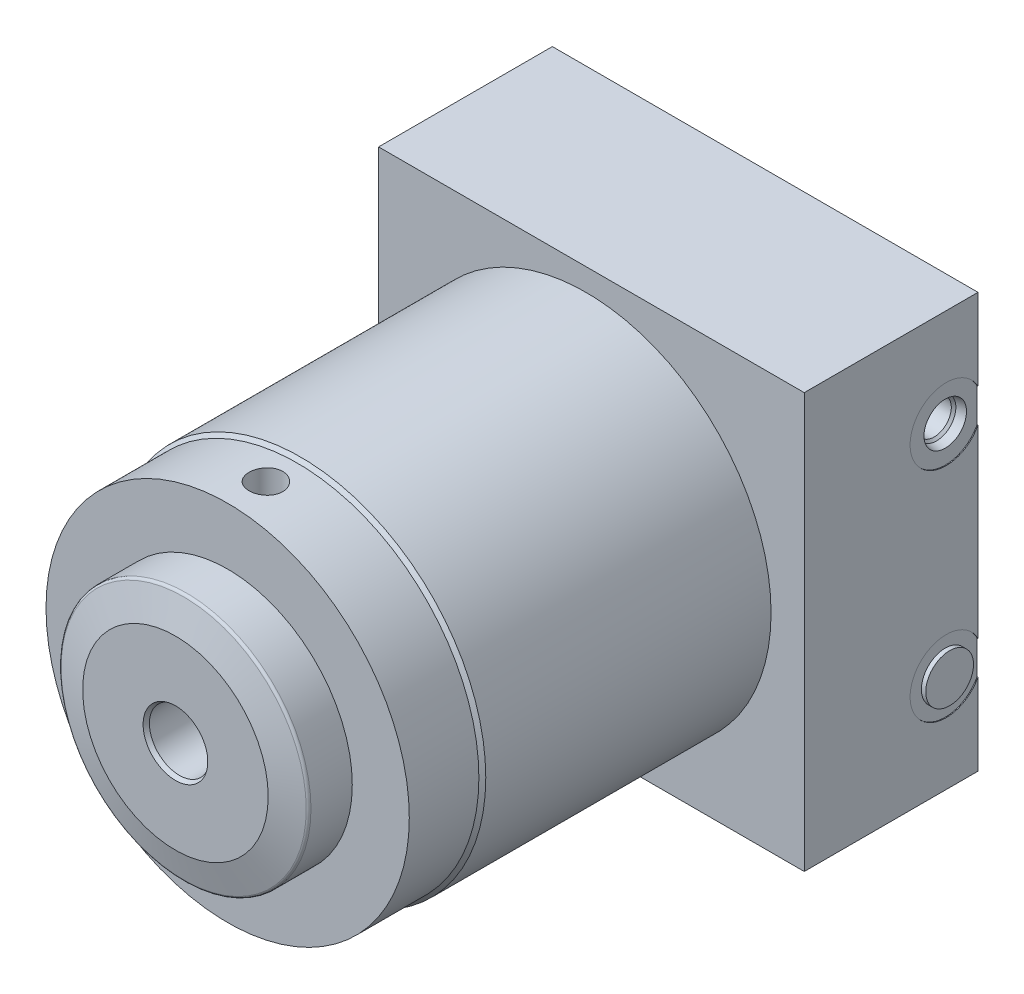
from build123d import *

# Parameters (mm, degrees)
SKETCH1_R           = 53.848
EXTRUDE1_DEPTH      = 127.7874
SKETCH13_W          = 15.1892
SKETCH13_H          = 36.2585
S2D0011_W           = 8.7376
S2D0011_H           = 18.034
SKETCH16_W          = 123.825
SKETCH16_H          = 50.546
EXTRUDE2_DEPTH      = 60.325
SKETCH17_R          = 10.4775
CUT_EXTRUDE9_DEPTH  = 0.254
SKETCH18_R          = 10.4775
CUT_EXTRUDE10_DEPTH = 0.254
SKETCH21_R          = 6.9469
EXTRUDE3_DEPTH      = 1.27
CHAMFER1_SIZE       = 1.1684
CHAMFER1_SIZE2      = 0.674576055


with BuildPart() as part:
    # Sketch1 → Extrude1 (new body)
    with BuildSketch(Plane.XY):
        Circle(SKETCH1_R)
    extrude(amount=EXTRUDE1_DEPTH)

    # Sketch10 → Cut-Revolve1 (revolve, cut)
    with BuildSketch(Plane(origin=(0, 0, 0), x_dir=(0, 0, -1), z_dir=(1, 0, 0)), mode=Mode.PRIVATE) as cut_revolve1_sk:
        Polygon((-127.7874, 52.8447), (-107.5436, 52.8447), (-106.5403, 53.848), (-127.7874, 53.848), align=None)
    revolve(cut_revolve1_sk.sketch.rotate(Axis((0, 0, 160.082178917), (0, 0, -1)), 90), axis=Axis((0, 0, 160.082178917), (0, 0, -1)), mode=Mode.SUBTRACT)  # turned: the seam where the file's is

    # Sketch13 → Revolve1 (revolve)
    with BuildSketch(Plane(origin=(0, 0, 0), x_dir=(0, 0, -1), z_dir=(1, 0, 0)), mode=Mode.PRIVATE) as revolve1_sk:
        with Locations((-135.382, 18.12925)):
            Rectangle(SKETCH13_W, SKETCH13_H)
    revolve(revolve1_sk.sketch.rotate(Axis((0, 0, 113.59896), (0, 0, -1)), 90), axis=Axis((0, 0, 113.59896), (0, 0, -1)))  # turned: the seam where the file's is

    # S2D0011 → Cut-Revolve4 (revolve, cut)
    with BuildSketch(Plane(origin=(-6.9342, 0, 112.8014), x_dir=(-1, 0, 0), z_dir=(0, 1, 0)), mode=Mode.PRIVATE) as cut_revolve4_sk:
        with Locations((-2.5654, 21.1582)):
            Rectangle(S2D0011_W, S2D0011_H)
    revolve(cut_revolve4_sk.sketch.rotate(Axis((0, 0, 106.5403), (0, 0, 1)), 180), axis=Axis((0, 0, 106.5403), (0, 0, 1)), mode=Mode.SUBTRACT)  # turned: the seam where the file's is

    # Sketch15 → Cut-Revolve5 (revolve, cut)
    with BuildSketch(Plane(origin=(0, 0, 0), x_dir=(0, 0, -1), z_dir=(1, 0, 0)), mode=Mode.PRIVATE) as cut_revolve5_sk:
        with BuildLine():
            Line((-142.9766, 26.9875), (-140.585166919, 35.66172482))
            ThreePointArc((-140.585166919, 35.66172482), (-140.294072774, 36.092317667), (-139.8016, 36.2585))
            Line((-139.8016, 36.2585), (-142.9766, 36.2585))
            Line((-142.9766, 36.2585), (-142.9766, 26.9875))
        make_face()
    revolve(cut_revolve5_sk.sketch.rotate(Axis((0, 0, 112.96015), (0, 0, -1)), 90), axis=Axis((0, 0, 112.96015), (0, 0, -1)), mode=Mode.SUBTRACT)  # turned: the seam where the file's is

    # Sketch16 → Extrude2 (add, symmetric)
    with BuildSketch(Plane(origin=(0, 0, 0), x_dir=(-1, 0, 0), z_dir=(0, 1, 0))):
        with Locations((-1.5875, -1.7272)):
            Rectangle(SKETCH16_W, SKETCH16_H)
    extrude(amount=EXTRUDE2_DEPTH, both=True)

    # Sketch17 → Cut-Extrude9 (cut)
    with BuildSketch(Plane(origin=(63.5, 0, 0), x_dir=(0, 0, -1), z_dir=(1, 0, 0))):
        with Locations((17.7292, -31.75)):
            Circle(SKETCH17_R)
    extrude(amount=-CUT_EXTRUDE9_DEPTH, mode=Mode.SUBTRACT)

    # Sketch18 → Cut-Extrude10 (cut)
    with BuildSketch(Plane(origin=(63.5, 0, 0), x_dir=(0, 0, -1), z_dir=(1, 0, 0))):
        with Locations((17.7292, 31.75)):
            Circle(SKETCH18_R)
    extrude(amount=-CUT_EXTRUDE10_DEPTH, mode=Mode.SUBTRACT)

    # S2D0001 → Cut-Revolve7 (revolve, cut)
    with BuildSketch(Plane(origin=(52.1462, 23.8125, -17.7292), x_dir=(0, -1, 0), z_dir=(0, 0, 1)), mode=Mode.PRIVATE) as cut_revolve7_sk:
        Polygon((-7.9375, 11.0998), (-1.7526, 11.0998), (-2.295193135, 8.5471), (-2.9591, 7.883193135), (-2.9591, -6.1722), (-7.9375, -6.1722), align=None)
    revolve(cut_revolve7_sk.sketch.rotate(Axis((34.0106, 31.75, -17.7292), (1, 0, 0)), 270), axis=Axis((34.0106, 31.75, -17.7292), (1, 0, 0)), mode=Mode.SUBTRACT)  # turned: the seam where the file's is

    # Sketch21 → Extrude3 (add)
    with BuildSketch(Plane(origin=(63.246, 0, 0), x_dir=(0, 0, -1), z_dir=(1, 0, 0))):
        with Locations((17.7292, -31.75)):
            Circle(SKETCH21_R)
    extrude(amount=EXTRUDE3_DEPTH)

    # Chamfer1
    chamfer1_edges = [part.edges().sort_by_distance(p)[0] for p in [
        (-8.7376, 0, 142.9766),
    ]]
    chamfer1_side = [part.faces().sort_by_distance(p)[0] for p in [
        (-8.7376, 0, 133.9596),
    ]]
    chamfer(chamfer1_edges, length=CHAMFER1_SIZE, length2=CHAMFER1_SIZE2, reference=chamfer1_side[0])

    # Sketch23 → Cut-Revolve8 (revolve, cut)
    with BuildSketch(Plane(origin=(0, 0, 0), x_dir=(0, 0, -1), z_dir=(1, 0, 0))):
        Polygon((-121.5517, 52.8447), (-121.5517, 44.9707), (-116.6622, 42.032792003), (-116.6622, 52.8447), align=None)
    cut_revolve8 = revolve(axis=Axis((0, 62.163785144, 116.6622), (0, -1, 0)), mode=Mode.SUBTRACT)

    # Mirror1: Cut-Revolve8 across plane
    add(cut_revolve8.mirror(Plane.ZX), mode=Mode.SUBTRACT)


solid = part.part
